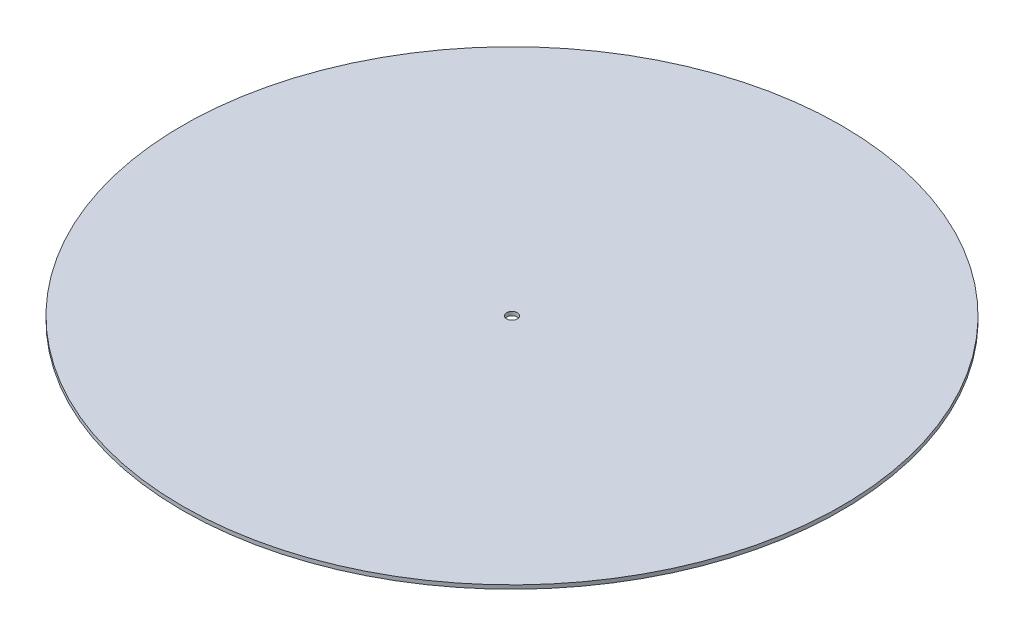
from build123d import *

# Parameters (mm, degrees)
SKETCH1_R           = 550
SKETCH1_R_2         = 9
BOSS_EXTRUDE1_DEPTH = 6.35


with BuildPart() as part:
    # Sketch1 → Boss-Extrude1 (new body)
    with BuildSketch(Plane(origin=(0, 0, 0), x_dir=(1, 0, 0), z_dir=(0, 1, 0))):
        Circle(SKETCH1_R)
        Circle(SKETCH1_R_2, mode=Mode.SUBTRACT)
    extrude(amount=BOSS_EXTRUDE1_DEPTH)


solid = part.part
